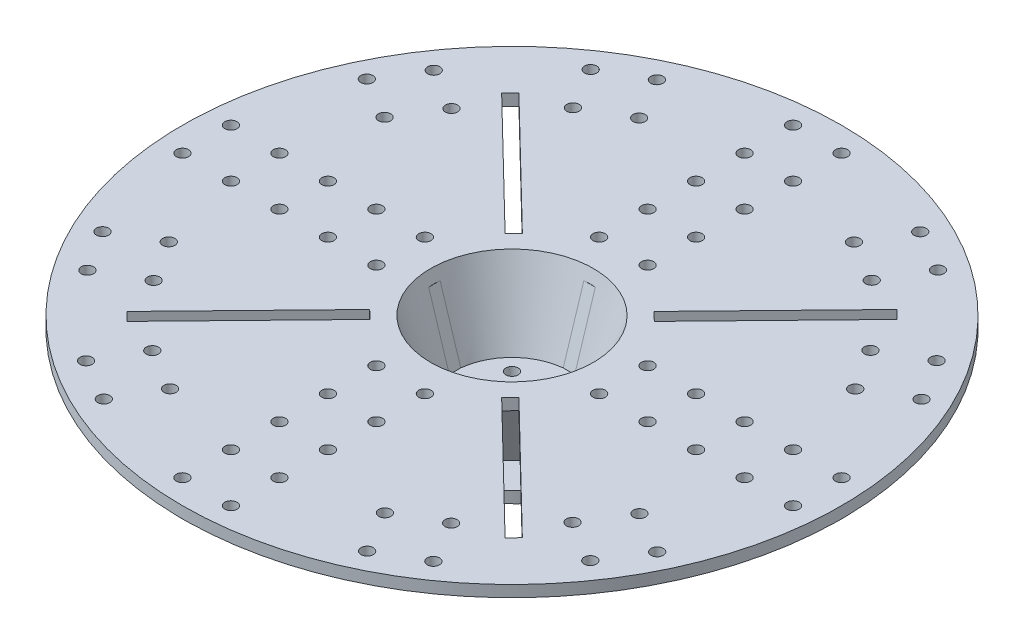
from build123d import *

# Parameters (mm, degrees)
BOSS_EXTRUDE2_DEPTH          = 3
CIRPATTERN2_COUNT            = 4
CUT_EXTRUDE3_DEPTH           = 6
CIRPATTERN4_COUNT            = 4
SKETCH7_W                    = 6
SKETCH7_H                    = 6
CUT_EXTRUDE4_DEPTH           = 34.25
SKETCH8_R                    = 3.175
CUT_EXTRUDE5_DEPTH           = 248.459028351
SKETCH11_R                   = 3.2
CUT_EXTRUDE6_DEPTH           = 248.459028351
LPATTERN2_COUNT              = 2
LPATTERN2_PITCH              = 25.4
LPATTERN2_COUNT_DIR2         = 5
LPATTERN2_PITCH_DIR2         = 25.4
CIRPATTERN5_COUNT            = 4
CIRPATTERN5_COPY_1_SKETCH_R  = 3.2
CIRPATTERN5_COPY_1_DEPTH     = 248.459028351
CIRPATTERN5_COPY_2_SKETCH_R  = 3.2
CIRPATTERN5_COPY_2_DEPTH     = 248.459028351
CIRPATTERN5_COPY_3_SKETCH_R  = 3.2
CIRPATTERN5_COPY_3_DEPTH     = 248.459028351
CIRPATTERN5_COPY_4_SKETCH_R  = 3.2
CIRPATTERN5_COPY_4_DEPTH     = 248.459028351
CIRPATTERN5_COPY_5_SKETCH_R  = 3.2
CIRPATTERN5_COPY_5_DEPTH     = 248.459028351
CIRPATTERN5_COPY_6_SKETCH_R  = 3.2
CIRPATTERN5_COPY_6_DEPTH     = 248.459028351
CIRPATTERN5_COPY_7_SKETCH_R  = 3.2
CIRPATTERN5_COPY_7_DEPTH     = 248.459028351
CIRPATTERN5_COPY_8_SKETCH_R  = 3.2
CIRPATTERN5_COPY_8_DEPTH     = 248.459028351
CIRPATTERN5_COPY_9_SKETCH_R  = 3.2
CIRPATTERN5_COPY_9_DEPTH     = 248.459028351
CIRPATTERN5_COPY_10_SKETCH_R = 3.2
CIRPATTERN5_COPY_10_DEPTH    = 248.459028351
CIRPATTERN5_COPY_11_SKETCH_R = 3.2
CIRPATTERN5_COPY_11_DEPTH    = 248.459028351
CIRPATTERN5_COPY_12_SKETCH_R = 3.2
CIRPATTERN5_COPY_12_DEPTH    = 248.459028351
CIRPATTERN5_COPY_13_SKETCH_R = 3.2
CIRPATTERN5_COPY_13_DEPTH    = 248.459028351
CIRPATTERN5_COPY_14_SKETCH_R = 3.2
CIRPATTERN5_COPY_14_DEPTH    = 248.459028351
CIRPATTERN5_COPY_15_SKETCH_R = 3.2
CIRPATTERN5_COPY_15_DEPTH    = 248.459028351
CIRPATTERN5_COPY_16_SKETCH_R = 3.2
CIRPATTERN5_COPY_16_DEPTH    = 248.459028351
CIRPATTERN5_COPY_17_SKETCH_R = 3.2
CIRPATTERN5_COPY_17_DEPTH    = 248.459028351
CIRPATTERN5_COPY_18_SKETCH_R = 3.2
CIRPATTERN5_COPY_18_DEPTH    = 248.459028351
CIRPATTERN5_COPY_19_SKETCH_R = 3.2
CIRPATTERN5_COPY_19_DEPTH    = 248.459028351
CIRPATTERN5_COPY_20_SKETCH_R = 3.2
CIRPATTERN5_COPY_20_DEPTH    = 248.459028351
CIRPATTERN5_COPY_21_SKETCH_R = 3.2
CIRPATTERN5_COPY_21_DEPTH    = 248.459028351
CIRPATTERN5_COPY_22_SKETCH_R = 3.2
CIRPATTERN5_COPY_22_DEPTH    = 248.459028351
CIRPATTERN5_COPY_23_SKETCH_R = 3.2
CIRPATTERN5_COPY_23_DEPTH    = 248.459028351
CIRPATTERN5_COPY_24_SKETCH_R = 3.2
CIRPATTERN5_COPY_24_DEPTH    = 248.459028351
CIRPATTERN5_COPY_25_SKETCH_R = 3.2
CIRPATTERN5_COPY_25_DEPTH    = 248.459028351
CIRPATTERN5_COPY_26_SKETCH_R = 3.2
CIRPATTERN5_COPY_26_DEPTH    = 248.459028351
CIRPATTERN5_COPY_27_SKETCH_R = 3.2
CIRPATTERN5_COPY_27_DEPTH    = 248.459028351
SKETCH17_R                   = 3.2
CUT_EXTRUDE7_DEPTH           = 249.50547421
LPATTERN3_COUNT              = 2
LPATTERN3_PITCH              = 25.4
LPATTERN3_COUNT_DIR2         = 2
LPATTERN3_PITCH_DIR2         = 25.4
MIRROR1_COPY_1_SKETCH_R      = 3.2
MIRROR1_COPY_1_DEPTH         = 249.50547421
MIRROR1_COPY_2_SKETCH_R      = 3.2
MIRROR1_COPY_2_DEPTH         = 249.50547421
MIRROR1_COPY_3_SKETCH_R      = 3.2
MIRROR1_COPY_3_DEPTH         = 249.50547421
MIRROR2_COPY_1_SKETCH_R      = 3.2
MIRROR2_COPY_1_DEPTH         = 249.50547421
MIRROR2_COPY_2_SKETCH_R      = 3.2
MIRROR2_COPY_2_DEPTH         = 249.50547421
MIRROR2_COPY_3_SKETCH_R      = 3.2
MIRROR2_COPY_3_DEPTH         = 249.50547421
MIRROR2_COPY_4_SKETCH_R      = 3.2
MIRROR2_COPY_4_DEPTH         = 249.50547421
MIRROR2_COPY_5_SKETCH_R      = 3.2
MIRROR2_COPY_5_DEPTH         = 249.50547421
MIRROR2_COPY_6_SKETCH_R      = 3.2
MIRROR2_COPY_6_DEPTH         = 249.50547421
MIRROR2_COPY_7_SKETCH_R      = 3.2
MIRROR2_COPY_7_DEPTH         = 249.50547421
CUT_EXTRUDE8_REACH           = 250.505
CIRPATTERN6_COUNT            = 4
SKETCH23_R                   = 3.2
CUT_EXTRUDE9_DEPTH           = 5.952869
CIRPATTERN7_COUNT            = 2
CIRPATTERN7_ANGLE            = 30
CIRPATTERN8_COUNT            = 4
CIRPATTERN8_COPY_1_SKETCH_R  = 3.2
CIRPATTERN8_COPY_1_DEPTH     = 5.952869
CIRPATTERN8_COPY_2_SKETCH_R  = 3.2
CIRPATTERN8_COPY_2_DEPTH     = 5.952869
CIRPATTERN8_COPY_3_SKETCH_R  = 3.2
CIRPATTERN8_COPY_3_DEPTH     = 5.952869
SKETCH26_R                   = 3.2
CUT_EXTRUDE10_DEPTH          = 249.50547421
LPATTERN4_COUNT              = 2
LPATTERN4_PITCH              = 25.4
LPATTERN4_COUNT_DIR2         = 2
LPATTERN4_PITCH_DIR2         = 25.4
MIRROR3_COPY_1_SKETCH_R      = 3.2
MIRROR3_COPY_1_DEPTH         = 249.50547421
MIRROR3_COPY_2_SKETCH_R      = 3.2
MIRROR3_COPY_2_DEPTH         = 249.50547421
MIRROR3_COPY_3_SKETCH_R      = 3.2
MIRROR3_COPY_3_DEPTH         = 249.50547421
MIRROR4_COPY_1_SKETCH_R      = 3.2
MIRROR4_COPY_1_DEPTH         = 249.50547421
MIRROR4_COPY_2_SKETCH_R      = 3.2
MIRROR4_COPY_2_DEPTH         = 249.50547421
MIRROR4_COPY_3_SKETCH_R      = 3.2
MIRROR4_COPY_3_DEPTH         = 249.50547421
MIRROR4_COPY_4_SKETCH_R      = 3.2
MIRROR4_COPY_4_DEPTH         = 249.50547421
MIRROR4_COPY_5_SKETCH_R      = 3.2
MIRROR4_COPY_5_DEPTH         = 249.50547421
MIRROR4_COPY_6_SKETCH_R      = 3.2
MIRROR4_COPY_6_DEPTH         = 249.50547421
MIRROR4_COPY_7_SKETCH_R      = 3.2
MIRROR4_COPY_7_DEPTH         = 249.50547421
CUT_EXTRUDE11_REACH          = 250.505
SKETCH27_R                   = 3.2
CIRPATTERN9_COUNT            = 4
CUT_EXTRUDE12_REACH          = 252.599
SKETCH28_W                   = 56
SKETCH28_H                   = 6.4
CIRPATTERN10_COUNT           = 4


with BuildPart() as part:
    # Sketch1 → Revolve2 (revolve)
    with BuildSketch(Plane.XY, mode=Mode.PRIVATE) as revolve2_sk:
        Polygon((0, -40.25), (0, -46.25), (55.5, -46.25), (55.5, -40.29713119), (36.117911549, -40.29713119), (46.896841146, -6), (172.649801929, -6), (172.649801929, 0), (42.649801929, 0), (30, -40.25), align=None)
    revolve(revolve2_sk.sketch.rotate(Axis((0, -40.25, 0), (0, -1, 0)), 90), axis=Axis((0, -40.25, 0), (0, -1, 0)))

    # Sketch3 → Boss-Extrude2 (add, symmetric)
    with BuildSketch(Plane.XY):
        Polygon((55.5, -40.29713119), (172.649801929, -6), (0, -6), (0, -40.29713119), align=None)
    boss_extrude2 = extrude(amount=BOSS_EXTRUDE2_DEPTH, both=True)

    # CirPattern2: Boss-Extrude2 ×4 about axis
    cirpattern2_axis = Axis((0, 0, 0), (0, 1, 0))
    for i in range(1, CIRPATTERN2_COUNT):
        add(boss_extrude2.rotate(cirpattern2_axis, i * 360 / CIRPATTERN2_COUNT))

    # Sketch6 → Cut-Extrude3 (cut)
    with BuildSketch(Plane.XY.offset(3)):
        Polygon((-3, -6), (-40.653576086, -6), (-29.849623113, -40.25), (-3, -40.25), align=None)
    cut_extrude3 = extrude(amount=-CUT_EXTRUDE3_DEPTH, mode=Mode.SUBTRACT)

    # CirPattern4: Cut-Extrude3 ×4 about axis
    cirpattern4_axis = Axis((0, 0, 0), (0, 1, 0))
    for i in range(1, CIRPATTERN4_COUNT):
        add(cut_extrude3.rotate(cirpattern4_axis, i * 360 / CIRPATTERN4_COUNT), mode=Mode.SUBTRACT)

    # Sketch7 → Cut-Extrude4 (cut)
    with BuildSketch(Plane(origin=(0, -6, 0), x_dir=(1, 0, 0), z_dir=(0, 1, 0))):
        Rectangle(SKETCH7_W, SKETCH7_H)
    extrude(amount=-CUT_EXTRUDE4_DEPTH, mode=Mode.SUBTRACT)

    # Sketch8 → Cut-Extrude5 (cut, through all)
    with BuildSketch(Plane(origin=(0, -40.25, 0), x_dir=(1, 0, 0), z_dir=(0, 1, 0))):
        with Locations(Location((0, 0, 0), (0, 0, 180))):
            Circle(SKETCH8_R)
    extrude(amount=-CUT_EXTRUDE5_DEPTH, mode=Mode.SUBTRACT)

    # Sketch11 → Cut-Extrude6 (cut, through all)
    with BuildSketch(Plane.XZ.offset(6)):
        with Locations((-12.7, 159.949801929)):
            Circle(SKETCH11_R)
    cut_extrude6 = extrude(amount=-CUT_EXTRUDE6_DEPTH, mode=Mode.SUBTRACT)

    # LPattern2: Cut-Extrude6 2 × 5
    with Locations(*[(i * LPATTERN2_PITCH, 0, -j * LPATTERN2_PITCH_DIR2) for i in range(LPATTERN2_COUNT) for j in range(LPATTERN2_COUNT_DIR2) if (i, j) != (0, 0)]):
        add(cut_extrude6, mode=Mode.SUBTRACT)

    # CirPattern5: Cut-Extrude6 ×4 about axis
    cirpattern5_axis = Axis((0, 0, 0), (0, 1, 0))
    for i in range(1, CIRPATTERN5_COUNT):
        add(cut_extrude6.rotate(cirpattern5_axis, i * 360 / CIRPATTERN5_COUNT), mode=Mode.SUBTRACT)

    # CirPattern5 copy 1 sketch → CirPattern5 copy 1 (cut, through all)
    with BuildSketch(Plane(origin=(-25.4, -6, 0), x_dir=(0, 0, -1), z_dir=(0, -1, 0))):
        with Locations((-12.7, 159.949801929)):
            Circle(CIRPATTERN5_COPY_1_SKETCH_R)
    extrude(amount=-CIRPATTERN5_COPY_1_DEPTH, mode=Mode.SUBTRACT)

    # CirPattern5 copy 2 sketch → CirPattern5 copy 2 (cut, through all)
    with BuildSketch(Plane(origin=(0, -6, 25.4), x_dir=(-1, 0, 0), z_dir=(0, -1, 0))):
        with Locations((-12.7, 159.949801929)):
            Circle(CIRPATTERN5_COPY_2_SKETCH_R)
    extrude(amount=-CIRPATTERN5_COPY_2_DEPTH, mode=Mode.SUBTRACT)

    # CirPattern5 copy 3 sketch → CirPattern5 copy 3 (cut, through all)
    with BuildSketch(Plane(origin=(25.4, -6, 0), x_dir=(0, 0, 1), z_dir=(0, -1, 0))):
        with Locations((-12.7, 159.949801929)):
            Circle(CIRPATTERN5_COPY_3_SKETCH_R)
    extrude(amount=-CIRPATTERN5_COPY_3_DEPTH, mode=Mode.SUBTRACT)

    # CirPattern5 copy 4 sketch → CirPattern5 copy 4 (cut, through all)
    with BuildSketch(Plane(origin=(-50.8, -6, 0), x_dir=(0, 0, -1), z_dir=(0, -1, 0))):
        with Locations((-12.7, 159.949801929)):
            Circle(CIRPATTERN5_COPY_4_SKETCH_R)
    extrude(amount=-CIRPATTERN5_COPY_4_DEPTH, mode=Mode.SUBTRACT)

    # CirPattern5 copy 5 sketch → CirPattern5 copy 5 (cut, through all)
    with BuildSketch(Plane(origin=(0, -6, 50.8), x_dir=(-1, 0, 0), z_dir=(0, -1, 0))):
        with Locations((-12.7, 159.949801929)):
            Circle(CIRPATTERN5_COPY_5_SKETCH_R)
    extrude(amount=-CIRPATTERN5_COPY_5_DEPTH, mode=Mode.SUBTRACT)

    # CirPattern5 copy 6 sketch → CirPattern5 copy 6 (cut, through all)
    with BuildSketch(Plane(origin=(50.8, -6, 0), x_dir=(0, 0, 1), z_dir=(0, -1, 0))):
        with Locations((-12.7, 159.949801929)):
            Circle(CIRPATTERN5_COPY_6_SKETCH_R)
    extrude(amount=-CIRPATTERN5_COPY_6_DEPTH, mode=Mode.SUBTRACT)

    # CirPattern5 copy 7 sketch → CirPattern5 copy 7 (cut, through all)
    with BuildSketch(Plane(origin=(-76.2, -6, 0), x_dir=(0, 0, -1), z_dir=(0, -1, 0))):
        with Locations((-12.7, 159.949801929)):
            Circle(CIRPATTERN5_COPY_7_SKETCH_R)
    extrude(amount=-CIRPATTERN5_COPY_7_DEPTH, mode=Mode.SUBTRACT)

    # CirPattern5 copy 8 sketch → CirPattern5 copy 8 (cut, through all)
    with BuildSketch(Plane(origin=(0, -6, 76.2), x_dir=(-1, 0, 0), z_dir=(0, -1, 0))):
        with Locations((-12.7, 159.949801929)):
            Circle(CIRPATTERN5_COPY_8_SKETCH_R)
    extrude(amount=-CIRPATTERN5_COPY_8_DEPTH, mode=Mode.SUBTRACT)

    # CirPattern5 copy 9 sketch → CirPattern5 copy 9 (cut, through all)
    with BuildSketch(Plane(origin=(76.2, -6, 0), x_dir=(0, 0, 1), z_dir=(0, -1, 0))):
        with Locations((-12.7, 159.949801929)):
            Circle(CIRPATTERN5_COPY_9_SKETCH_R)
    extrude(amount=-CIRPATTERN5_COPY_9_DEPTH, mode=Mode.SUBTRACT)

    # CirPattern5 copy 10 sketch → CirPattern5 copy 10 (cut, through all)
    with BuildSketch(Plane(origin=(-101.6, -6, 0), x_dir=(0, 0, -1), z_dir=(0, -1, 0))):
        with Locations((-12.7, 159.949801929)):
            Circle(CIRPATTERN5_COPY_10_SKETCH_R)
    extrude(amount=-CIRPATTERN5_COPY_10_DEPTH, mode=Mode.SUBTRACT)

    # CirPattern5 copy 11 sketch → CirPattern5 copy 11 (cut, through all)
    with BuildSketch(Plane(origin=(0, -6, 101.6), x_dir=(-1, 0, 0), z_dir=(0, -1, 0))):
        with Locations((-12.7, 159.949801929)):
            Circle(CIRPATTERN5_COPY_11_SKETCH_R)
    extrude(amount=-CIRPATTERN5_COPY_11_DEPTH, mode=Mode.SUBTRACT)

    # CirPattern5 copy 12 sketch → CirPattern5 copy 12 (cut, through all)
    with BuildSketch(Plane(origin=(101.6, -6, 0), x_dir=(0, 0, 1), z_dir=(0, -1, 0))):
        with Locations((-12.7, 159.949801929)):
            Circle(CIRPATTERN5_COPY_12_SKETCH_R)
    extrude(amount=-CIRPATTERN5_COPY_12_DEPTH, mode=Mode.SUBTRACT)

    # CirPattern5 copy 13 sketch → CirPattern5 copy 13 (cut, through all)
    with BuildSketch(Plane(origin=(0, -6, -25.4), x_dir=(0, 0, -1), z_dir=(0, -1, 0))):
        with Locations((-12.7, 159.949801929)):
            Circle(CIRPATTERN5_COPY_13_SKETCH_R)
    extrude(amount=-CIRPATTERN5_COPY_13_DEPTH, mode=Mode.SUBTRACT)

    # CirPattern5 copy 14 sketch → CirPattern5 copy 14 (cut, through all)
    with BuildSketch(Plane(origin=(-25.4, -6, 0), x_dir=(-1, 0, 0), z_dir=(0, -1, 0))):
        with Locations((-12.7, 159.949801929)):
            Circle(CIRPATTERN5_COPY_14_SKETCH_R)
    extrude(amount=-CIRPATTERN5_COPY_14_DEPTH, mode=Mode.SUBTRACT)

    # CirPattern5 copy 15 sketch → CirPattern5 copy 15 (cut, through all)
    with BuildSketch(Plane(origin=(0, -6, 25.4), x_dir=(0, 0, 1), z_dir=(0, -1, 0))):
        with Locations((-12.7, 159.949801929)):
            Circle(CIRPATTERN5_COPY_15_SKETCH_R)
    extrude(amount=-CIRPATTERN5_COPY_15_DEPTH, mode=Mode.SUBTRACT)

    # CirPattern5 copy 16 sketch → CirPattern5 copy 16 (cut, through all)
    with BuildSketch(Plane(origin=(-25.4, -6, -25.4), x_dir=(0, 0, -1), z_dir=(0, -1, 0))):
        with Locations((-12.7, 159.949801929)):
            Circle(CIRPATTERN5_COPY_16_SKETCH_R)
    extrude(amount=-CIRPATTERN5_COPY_16_DEPTH, mode=Mode.SUBTRACT)

    # CirPattern5 copy 17 sketch → CirPattern5 copy 17 (cut, through all)
    with BuildSketch(Plane(origin=(-25.4, -6, 25.4), x_dir=(-1, 0, 0), z_dir=(0, -1, 0))):
        with Locations((-12.7, 159.949801929)):
            Circle(CIRPATTERN5_COPY_17_SKETCH_R)
    extrude(amount=-CIRPATTERN5_COPY_17_DEPTH, mode=Mode.SUBTRACT)

    # CirPattern5 copy 18 sketch → CirPattern5 copy 18 (cut, through all)
    with BuildSketch(Plane(origin=(25.4, -6, 25.4), x_dir=(0, 0, 1), z_dir=(0, -1, 0))):
        with Locations((-12.7, 159.949801929)):
            Circle(CIRPATTERN5_COPY_18_SKETCH_R)
    extrude(amount=-CIRPATTERN5_COPY_18_DEPTH, mode=Mode.SUBTRACT)

    # CirPattern5 copy 19 sketch → CirPattern5 copy 19 (cut, through all)
    with BuildSketch(Plane(origin=(-50.8, -6, -25.4), x_dir=(0, 0, -1), z_dir=(0, -1, 0))):
        with Locations((-12.7, 159.949801929)):
            Circle(CIRPATTERN5_COPY_19_SKETCH_R)
    extrude(amount=-CIRPATTERN5_COPY_19_DEPTH, mode=Mode.SUBTRACT)

    # CirPattern5 copy 20 sketch → CirPattern5 copy 20 (cut, through all)
    with BuildSketch(Plane(origin=(-25.4, -6, 50.8), x_dir=(-1, 0, 0), z_dir=(0, -1, 0))):
        with Locations((-12.7, 159.949801929)):
            Circle(CIRPATTERN5_COPY_20_SKETCH_R)
    extrude(amount=-CIRPATTERN5_COPY_20_DEPTH, mode=Mode.SUBTRACT)

    # CirPattern5 copy 21 sketch → CirPattern5 copy 21 (cut, through all)
    with BuildSketch(Plane(origin=(50.8, -6, 25.4), x_dir=(0, 0, 1), z_dir=(0, -1, 0))):
        with Locations((-12.7, 159.949801929)):
            Circle(CIRPATTERN5_COPY_21_SKETCH_R)
    extrude(amount=-CIRPATTERN5_COPY_21_DEPTH, mode=Mode.SUBTRACT)

    # CirPattern5 copy 22 sketch → CirPattern5 copy 22 (cut, through all)
    with BuildSketch(Plane(origin=(-76.2, -6, -25.4), x_dir=(0, 0, -1), z_dir=(0, -1, 0))):
        with Locations((-12.7, 159.949801929)):
            Circle(CIRPATTERN5_COPY_22_SKETCH_R)
    extrude(amount=-CIRPATTERN5_COPY_22_DEPTH, mode=Mode.SUBTRACT)

    # CirPattern5 copy 23 sketch → CirPattern5 copy 23 (cut, through all)
    with BuildSketch(Plane(origin=(-25.4, -6, 76.2), x_dir=(-1, 0, 0), z_dir=(0, -1, 0))):
        with Locations((-12.7, 159.949801929)):
            Circle(CIRPATTERN5_COPY_23_SKETCH_R)
    extrude(amount=-CIRPATTERN5_COPY_23_DEPTH, mode=Mode.SUBTRACT)

    # CirPattern5 copy 24 sketch → CirPattern5 copy 24 (cut, through all)
    with BuildSketch(Plane(origin=(76.2, -6, 25.4), x_dir=(0, 0, 1), z_dir=(0, -1, 0))):
        with Locations((-12.7, 159.949801929)):
            Circle(CIRPATTERN5_COPY_24_SKETCH_R)
    extrude(amount=-CIRPATTERN5_COPY_24_DEPTH, mode=Mode.SUBTRACT)

    # CirPattern5 copy 25 sketch → CirPattern5 copy 25 (cut, through all)
    with BuildSketch(Plane(origin=(-101.6, -6, -25.4), x_dir=(0, 0, -1), z_dir=(0, -1, 0))):
        with Locations((-12.7, 159.949801929)):
            Circle(CIRPATTERN5_COPY_25_SKETCH_R)
    extrude(amount=-CIRPATTERN5_COPY_25_DEPTH, mode=Mode.SUBTRACT)

    # CirPattern5 copy 26 sketch → CirPattern5 copy 26 (cut, through all)
    with BuildSketch(Plane(origin=(-25.4, -6, 101.6), x_dir=(-1, 0, 0), z_dir=(0, -1, 0))):
        with Locations((-12.7, 159.949801929)):
            Circle(CIRPATTERN5_COPY_26_SKETCH_R)
    extrude(amount=-CIRPATTERN5_COPY_26_DEPTH, mode=Mode.SUBTRACT)

    # CirPattern5 copy 27 sketch → CirPattern5 copy 27 (cut, through all)
    with BuildSketch(Plane(origin=(101.6, -6, 25.4), x_dir=(0, 0, 1), z_dir=(0, -1, 0))):
        with Locations((-12.7, 159.949801929)):
            Circle(CIRPATTERN5_COPY_27_SKETCH_R)
    extrude(amount=-CIRPATTERN5_COPY_27_DEPTH, mode=Mode.SUBTRACT)

    # Sketch17 → Cut-Extrude7 (cut, through all)
    with BuildSketch(Plane(origin=(0, 0, 0), x_dir=(1, 0, 0), z_dir=(0, 1, 0))):
        with Locations(Location((131.730527259, -90.719352211, 0), (0, 0, 180))):
            Circle(SKETCH17_R)
    cut_extrude7 = extrude(amount=-CUT_EXTRUDE7_DEPTH, mode=Mode.SUBTRACT)

    # LPattern3: Cut-Extrude7 2 × 2
    with Locations(*[Vector(-0.866025403784438, 0, -0.5000000000000012) * (i * LPATTERN3_PITCH) + Vector(0.5335735431738399, 0, -0.8457536721912087) * (j * LPATTERN3_PITCH_DIR2) for i in range(LPATTERN3_COUNT) for j in range(LPATTERN3_COUNT_DIR2) if (i, j) != (0, 0)]):
        add(cut_extrude7, mode=Mode.SUBTRACT)

    # Mirror1: Cut-Extrude7 across plane
    add(cut_extrude7.mirror(Plane(origin=(0, 0, 0), x_dir=(0, 0, 1), z_dir=(1, 0, 0))), mode=Mode.SUBTRACT)

    # Mirror1 copy 1 sketch → Mirror1 copy 1 (cut, through all)
    with BuildSketch(Plane(origin=(-13.552767997, 0, -21.482143274), x_dir=(-1, 0, 0), z_dir=(0, 1, 0))):
        with Locations((131.730527259, 90.719352211)):
            Circle(MIRROR1_COPY_1_SKETCH_R)
    extrude(amount=-MIRROR1_COPY_1_DEPTH, mode=Mode.SUBTRACT)

    # Mirror1 copy 2 sketch → Mirror1 copy 2 (cut, through all)
    with BuildSketch(Plane(origin=(21.997045256, 0, -12.7), x_dir=(-1, 0, 0), z_dir=(0, 1, 0))):
        with Locations((131.730527259, 90.719352211)):
            Circle(MIRROR1_COPY_2_SKETCH_R)
    extrude(amount=-MIRROR1_COPY_2_DEPTH, mode=Mode.SUBTRACT)

    # Mirror1 copy 3 sketch → Mirror1 copy 3 (cut, through all)
    with BuildSketch(Plane(origin=(8.44427726, 0, -34.182143274), x_dir=(-1, 0, 0), z_dir=(0, 1, 0))):
        with Locations((131.730527259, 90.719352211)):
            Circle(MIRROR1_COPY_3_SKETCH_R)
    extrude(amount=-MIRROR1_COPY_3_DEPTH, mode=Mode.SUBTRACT)

    # Mirror2: Cut-Extrude7 across plane
    add(cut_extrude7.mirror(Plane.XY), mode=Mode.SUBTRACT)

    # Mirror2 copy 1 sketch → Mirror2 copy 1 (cut, through all)
    with BuildSketch(Plane(origin=(13.552767997, 0, 21.482143274), x_dir=(1, 0, 0), z_dir=(0, 1, 0))):
        with Locations((131.730527259, 90.719352211)):
            Circle(MIRROR2_COPY_1_SKETCH_R)
    extrude(amount=-MIRROR2_COPY_1_DEPTH, mode=Mode.SUBTRACT)

    # Mirror2 copy 2 sketch → Mirror2 copy 2 (cut, through all)
    with BuildSketch(Plane(origin=(-21.997045256, 0, 12.7), x_dir=(1, 0, 0), z_dir=(0, 1, 0))):
        with Locations((131.730527259, 90.719352211)):
            Circle(MIRROR2_COPY_2_SKETCH_R)
    extrude(amount=-MIRROR2_COPY_2_DEPTH, mode=Mode.SUBTRACT)

    # Mirror2 copy 3 sketch → Mirror2 copy 3 (cut, through all)
    with BuildSketch(Plane(origin=(-8.44427726, 0, 34.182143274), x_dir=(1, 0, 0), z_dir=(0, 1, 0))):
        with Locations((131.730527259, 90.719352211)):
            Circle(MIRROR2_COPY_3_SKETCH_R)
    extrude(amount=-MIRROR2_COPY_3_DEPTH, mode=Mode.SUBTRACT)

    # Mirror2 copy 4 sketch → Mirror2 copy 4 (cut, through all)
    with BuildSketch(Plane(origin=(0, 0, 0), x_dir=(-1, 0, 0), z_dir=(0, 1, 0))):
        with Locations(Location((131.730527259, -90.719352211, 0), (0, 0, 180))):
            Circle(MIRROR2_COPY_4_SKETCH_R)
    extrude(amount=-MIRROR2_COPY_4_DEPTH, mode=Mode.SUBTRACT)

    # Mirror2 copy 5 sketch → Mirror2 copy 5 (cut, through all)
    with BuildSketch(Plane(origin=(-13.552767997, 0, 21.482143274), x_dir=(-1, 0, 0), z_dir=(0, 1, 0))):
        with Locations(Location((131.730527259, -90.719352211, 0), (0, 0, 180))):
            Circle(MIRROR2_COPY_5_SKETCH_R)
    extrude(amount=-MIRROR2_COPY_5_DEPTH, mode=Mode.SUBTRACT)

    # Mirror2 copy 6 sketch → Mirror2 copy 6 (cut, through all)
    with BuildSketch(Plane(origin=(21.997045256, 0, 12.7), x_dir=(-1, 0, 0), z_dir=(0, 1, 0))):
        with Locations(Location((131.730527259, -90.719352211, 0), (0, 0, 180))):
            Circle(MIRROR2_COPY_6_SKETCH_R)
    extrude(amount=-MIRROR2_COPY_6_DEPTH, mode=Mode.SUBTRACT)

    # Mirror2 copy 7 sketch → Mirror2 copy 7 (cut, through all)
    with BuildSketch(Plane(origin=(8.44427726, 0, 34.182143274), x_dir=(-1, 0, 0), z_dir=(0, 1, 0))):
        with Locations(Location((131.730527259, -90.719352211, 0), (0, 0, 180))):
            Circle(MIRROR2_COPY_7_SKETCH_R)
    extrude(amount=-MIRROR2_COPY_7_DEPTH, mode=Mode.SUBTRACT)

    # Sketch19 → Cut-Extrude8 (cut, up to next)
    with BuildSketch(Plane(origin=(0, 0, 0), x_dir=(1, 0, 0), z_dir=(0, 1, 0)), mode=Mode.PRIVATE) as cut_extrude8_sk1:
        Polygon((102.718357979, 99.092422248), (98.129358862, 103.553485697), (35.395654106, 39.020685605), (39.984653224, 34.559622156), align=None)
    cut_extrude8_tool1 = extrude(cut_extrude8_sk1.sketch, amount=-CUT_EXTRUDE8_REACH, mode=Mode.PRIVATE) & part.part
    cut_extrude8 = cut_extrude8_tool1.solids().sort_by_distance((69.057006, 0, -69.056554))[0]
    add(cut_extrude8, mode=Mode.SUBTRACT)

    # CirPattern6: Cut-Extrude8 ×4 about axis
    cirpattern6_axis = Axis((0, 0, 0), (0, 1, 0))
    for i in range(1, CIRPATTERN6_COUNT):
        add(cut_extrude8.rotate(cirpattern6_axis, i * 360 / CIRPATTERN6_COUNT), mode=Mode.SUBTRACT)

    # Sketch23 → Cut-Extrude9 (cut)
    with BuildSketch(Plane.XZ.offset(46.25)):
        with Locations(Location((23, -39.837168574, 0), (0, 0, 270))):
            Circle(SKETCH23_R)
    cut_extrude9 = extrude(amount=-CUT_EXTRUDE9_DEPTH, mode=Mode.SUBTRACT)

    # CirPattern7: Cut-Extrude9 ×2 about axis
    cirpattern7_axis = Axis((0, 0, 0), (0, -1, 0))
    for i in range(1, CIRPATTERN7_COUNT):
        add(cut_extrude9.rotate(cirpattern7_axis, i * CIRPATTERN7_ANGLE / (CIRPATTERN7_COUNT - 1)), mode=Mode.SUBTRACT)

    # CirPattern8: Cut-Extrude9 ×4 about axis
    cirpattern8_axis = Axis((0, 0, 0), (0, 1, 0))
    for i in range(1, CIRPATTERN8_COUNT):
        add(cut_extrude9.rotate(cirpattern8_axis, i * 360 / CIRPATTERN8_COUNT), mode=Mode.SUBTRACT)

    # CirPattern8 copy 1 sketch → CirPattern8 copy 1 (cut)
    with BuildSketch(Plane(origin=(0, -46.25, 0), x_dir=(0.5000000000000011, 0, -0.866025403784438), z_dir=(0, -1, 0))):
        with Locations(Location((23, -39.837168574, 0), (0, 0, 270))):
            Circle(CIRPATTERN8_COPY_1_SKETCH_R)
    extrude(amount=-CIRPATTERN8_COPY_1_DEPTH, mode=Mode.SUBTRACT)

    # CirPattern8 copy 2 sketch → CirPattern8 copy 2 (cut)
    with BuildSketch(Plane(origin=(0, -46.25, 0), x_dir=(-0.8660254037844379, 0, -0.5000000000000012), z_dir=(0, -1, 0))):
        with Locations(Location((23, -39.837168574, 0), (0, 0, 270))):
            Circle(CIRPATTERN8_COPY_2_SKETCH_R)
    extrude(amount=-CIRPATTERN8_COPY_2_DEPTH, mode=Mode.SUBTRACT)

    # CirPattern8 copy 3 sketch → CirPattern8 copy 3 (cut)
    with BuildSketch(Plane(origin=(0, -46.25, 0), x_dir=(-0.5000000000000012, 0, 0.8660254037844379), z_dir=(0, -1, 0))):
        with Locations(Location((23, -39.837168574, 0), (0, 0, 270))):
            Circle(CIRPATTERN8_COPY_3_SKETCH_R)
    extrude(amount=-CIRPATTERN8_COPY_3_DEPTH, mode=Mode.SUBTRACT)

    # Sketch26 → Cut-Extrude10 (cut, through all)
    with BuildSketch(Plane(origin=(0, 0, 0), x_dir=(1, 0, 0), z_dir=(0, 1, 0))):
        with Locations(Location((68.976378337, -144.870591801, 0), (0, 0, 180))):
            Circle(SKETCH26_R)
    cut_extrude10 = extrude(amount=-CUT_EXTRUDE10_DEPTH, mode=Mode.SUBTRACT)

    # LPattern4: Cut-Extrude10 2 × 2
    with Locations(*[Vector(-0.500000000000001, 0, -0.866025403784438) * (i * LPATTERN4_PITCH) + Vector(0.866025403784439, 0, -0.4999999999999995) * (j * LPATTERN4_PITCH_DIR2) for i in range(LPATTERN4_COUNT) for j in range(LPATTERN4_COUNT_DIR2) if (i, j) != (0, 0)]):
        add(cut_extrude10, mode=Mode.SUBTRACT)

    # Mirror3: Cut-Extrude10 across plane
    add(cut_extrude10.mirror(Plane(origin=(0, 0, 0), x_dir=(0, 0, 1), z_dir=(1, 0, 0))), mode=Mode.SUBTRACT)

    # Mirror3 copy 1 sketch → Mirror3 copy 1 (cut, through all)
    with BuildSketch(Plane(origin=(-21.997045256, 0, -12.7), x_dir=(-1, 0, 0), z_dir=(0, 1, 0))):
        with Locations((68.976378337, 144.870591801)):
            Circle(MIRROR3_COPY_1_SKETCH_R)
    extrude(amount=-MIRROR3_COPY_1_DEPTH, mode=Mode.SUBTRACT)

    # Mirror3 copy 2 sketch → Mirror3 copy 2 (cut, through all)
    with BuildSketch(Plane(origin=(12.7, 0, -21.997045256), x_dir=(-1, 0, 0), z_dir=(0, 1, 0))):
        with Locations((68.976378337, 144.870591801)):
            Circle(MIRROR3_COPY_2_SKETCH_R)
    extrude(amount=-MIRROR3_COPY_2_DEPTH, mode=Mode.SUBTRACT)

    # Mirror3 copy 3 sketch → Mirror3 copy 3 (cut, through all)
    with BuildSketch(Plane(origin=(-9.297045256, 0, -34.697045256), x_dir=(-1, 0, 0), z_dir=(0, 1, 0))):
        with Locations((68.976378337, 144.870591801)):
            Circle(MIRROR3_COPY_3_SKETCH_R)
    extrude(amount=-MIRROR3_COPY_3_DEPTH, mode=Mode.SUBTRACT)

    # Mirror4: Cut-Extrude10 across plane
    add(cut_extrude10.mirror(Plane.XY), mode=Mode.SUBTRACT)

    # Mirror4 copy 1 sketch → Mirror4 copy 1 (cut, through all)
    with BuildSketch(Plane(origin=(21.997045256, 0, 12.7), x_dir=(1, 0, 0), z_dir=(0, 1, 0))):
        with Locations((68.976378337, 144.870591801)):
            Circle(MIRROR4_COPY_1_SKETCH_R)
    extrude(amount=-MIRROR4_COPY_1_DEPTH, mode=Mode.SUBTRACT)

    # Mirror4 copy 2 sketch → Mirror4 copy 2 (cut, through all)
    with BuildSketch(Plane(origin=(-12.7, 0, 21.997045256), x_dir=(1, 0, 0), z_dir=(0, 1, 0))):
        with Locations((68.976378337, 144.870591801)):
            Circle(MIRROR4_COPY_2_SKETCH_R)
    extrude(amount=-MIRROR4_COPY_2_DEPTH, mode=Mode.SUBTRACT)

    # Mirror4 copy 3 sketch → Mirror4 copy 3 (cut, through all)
    with BuildSketch(Plane(origin=(9.297045256, 0, 34.697045256), x_dir=(1, 0, 0), z_dir=(0, 1, 0))):
        with Locations((68.976378337, 144.870591801)):
            Circle(MIRROR4_COPY_3_SKETCH_R)
    extrude(amount=-MIRROR4_COPY_3_DEPTH, mode=Mode.SUBTRACT)

    # Mirror4 copy 4 sketch → Mirror4 copy 4 (cut, through all)
    with BuildSketch(Plane(origin=(0, 0, 0), x_dir=(-1, 0, 0), z_dir=(0, 1, 0))):
        with Locations(Location((68.976378337, -144.870591801, 0), (0, 0, 180))):
            Circle(MIRROR4_COPY_4_SKETCH_R)
    extrude(amount=-MIRROR4_COPY_4_DEPTH, mode=Mode.SUBTRACT)

    # Mirror4 copy 5 sketch → Mirror4 copy 5 (cut, through all)
    with BuildSketch(Plane(origin=(-21.997045256, 0, 12.7), x_dir=(-1, 0, 0), z_dir=(0, 1, 0))):
        with Locations(Location((68.976378337, -144.870591801, 0), (0, 0, 180))):
            Circle(MIRROR4_COPY_5_SKETCH_R)
    extrude(amount=-MIRROR4_COPY_5_DEPTH, mode=Mode.SUBTRACT)

    # Mirror4 copy 6 sketch → Mirror4 copy 6 (cut, through all)
    with BuildSketch(Plane(origin=(12.7, 0, 21.997045256), x_dir=(-1, 0, 0), z_dir=(0, 1, 0))):
        with Locations(Location((68.976378337, -144.870591801, 0), (0, 0, 180))):
            Circle(MIRROR4_COPY_6_SKETCH_R)
    extrude(amount=-MIRROR4_COPY_6_DEPTH, mode=Mode.SUBTRACT)

    # Mirror4 copy 7 sketch → Mirror4 copy 7 (cut, through all)
    with BuildSketch(Plane(origin=(-9.297045256, 0, 34.697045256), x_dir=(-1, 0, 0), z_dir=(0, 1, 0))):
        with Locations(Location((68.976378337, -144.870591801, 0), (0, 0, 180))):
            Circle(MIRROR4_COPY_7_SKETCH_R)
    extrude(amount=-MIRROR4_COPY_7_DEPTH, mode=Mode.SUBTRACT)

    # Sketch27 → Cut-Extrude11 (cut, up to next)
    with BuildSketch(Plane.XZ.offset(46.25), mode=Mode.PRIVATE) as cut_extrude11_sk1:
        with Locations((14.849242405, -14.849242405)):
            Circle(SKETCH27_R)
    cut_extrude11_tool1 = extrude(cut_extrude11_sk1.sketch, amount=-CUT_EXTRUDE11_REACH, mode=Mode.PRIVATE) & part.part
    cut_extrude11 = cut_extrude11_tool1.solids().sort_by_distance((14.849242, -46.25, -14.849242))[0]
    add(cut_extrude11, mode=Mode.SUBTRACT)

    # CirPattern9: Cut-Extrude11 ×4 about axis
    cirpattern9_axis = Axis((0, 0, 0), (0, 1, 0))
    for i in range(1, CIRPATTERN9_COUNT):
        add(cut_extrude11.rotate(cirpattern9_axis, i * 360 / CIRPATTERN9_COUNT), mode=Mode.SUBTRACT)

    # Sketch28 → Cut-Extrude12 (cut, up to next)
    with BuildSketch(Plane(origin=(3, 0, 0), x_dir=(0, 0, -1), z_dir=(1, 0, 0)), mode=Mode.PRIVATE) as cut_extrude12_sk1:
        with Locations((79, -15.6)):
            Rectangle(SKETCH28_W, SKETCH28_H)
    cut_extrude12_tool1 = extrude(cut_extrude12_sk1.sketch, amount=-CUT_EXTRUDE12_REACH, mode=Mode.PRIVATE) & part.part
    cut_extrude12 = cut_extrude12_tool1.solids().sort_by_distance((3, -15.6, -79))[0]
    add(cut_extrude12, mode=Mode.SUBTRACT)

    # CirPattern10: Cut-Extrude12 ×4 about axis
    cirpattern10_axis = Axis((0, 0, 0), (0, 1, 0))
    for i in range(1, CIRPATTERN10_COUNT):
        add(cut_extrude12.rotate(cirpattern10_axis, i * 360 / CIRPATTERN10_COUNT), mode=Mode.SUBTRACT)


solid = part.part
